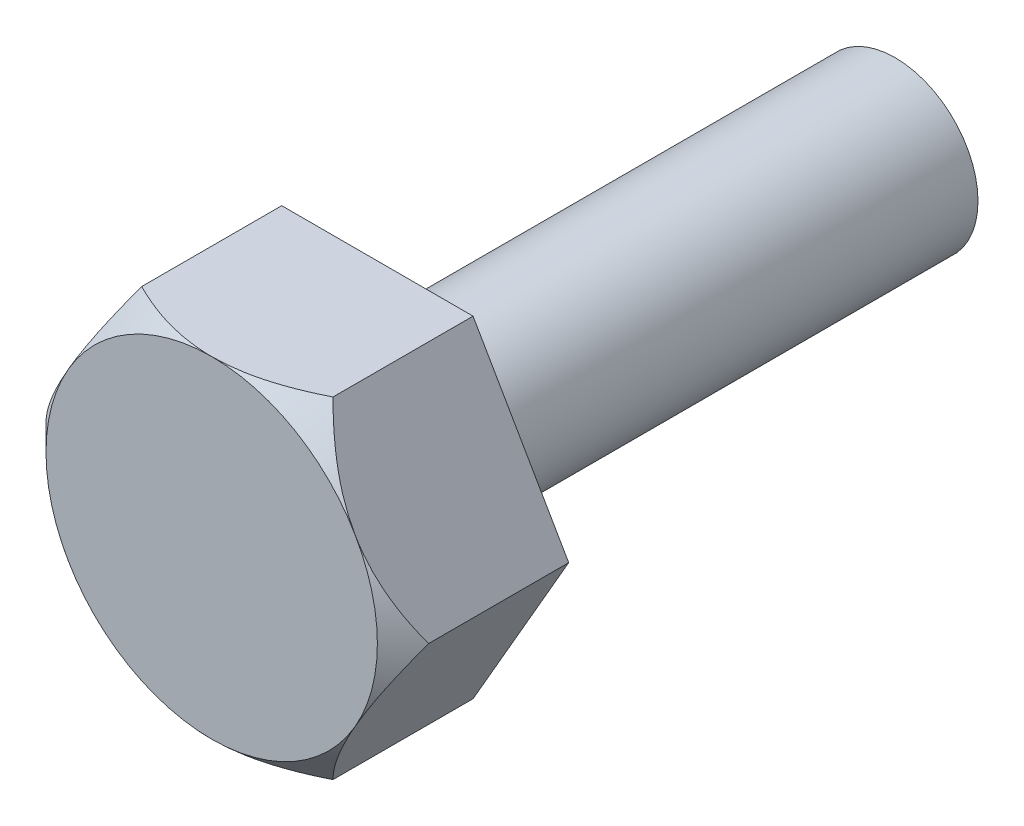
from build123d import *

# Parameters (mm, degrees)
BOSS_EXTRUDE1_DEPTH = 8
SKETCH2_OUTSIDE_W   = 41.62
SKETCH2_OUTSIDE_H   = 39.144
SKETCH2_OUTSIDE_R   = 8
CUT_EXTRUDE1_DEPTH  = 8
CUT_EXTRUDE1_TAPER  = 45
SKETCH3_R           = 4
BOSS_EXTRUDE2_DEPTH = 25


with BuildPart() as part:
    # Sketch1 → Boss-Extrude1 (new body)
    with BuildSketch(Plane.XY):
        Polygon((9.237604307, 0), (4.618802154, 8), (-4.618802154, 8), (-9.237604307, 0), (-4.618802154, -8), (4.618802154, -8), align=None)
    extrude(amount=BOSS_EXTRUDE1_DEPTH)

    # Sketch2 outside → Cut-Extrude1 (cut)
    with BuildSketch(Plane.XY.offset(8)):
        Rectangle(SKETCH2_OUTSIDE_W, SKETCH2_OUTSIDE_H)
        Circle(SKETCH2_OUTSIDE_R, mode=Mode.SUBTRACT)
    extrude(amount=-CUT_EXTRUDE1_DEPTH, taper=CUT_EXTRUDE1_TAPER, mode=Mode.SUBTRACT)

    # Sketch3 → Boss-Extrude2 (add)
    with BuildSketch(Plane(origin=(0, 0, 0), x_dir=(-1, 0, 0), z_dir=(0, 0, -1))):
        with Locations(Location((0, 0, 0), (0, 0, 180))):  # turned: the seam where the file's is
            Circle(SKETCH3_R)
    extrude(amount=BOSS_EXTRUDE2_DEPTH)


solid = part.part
